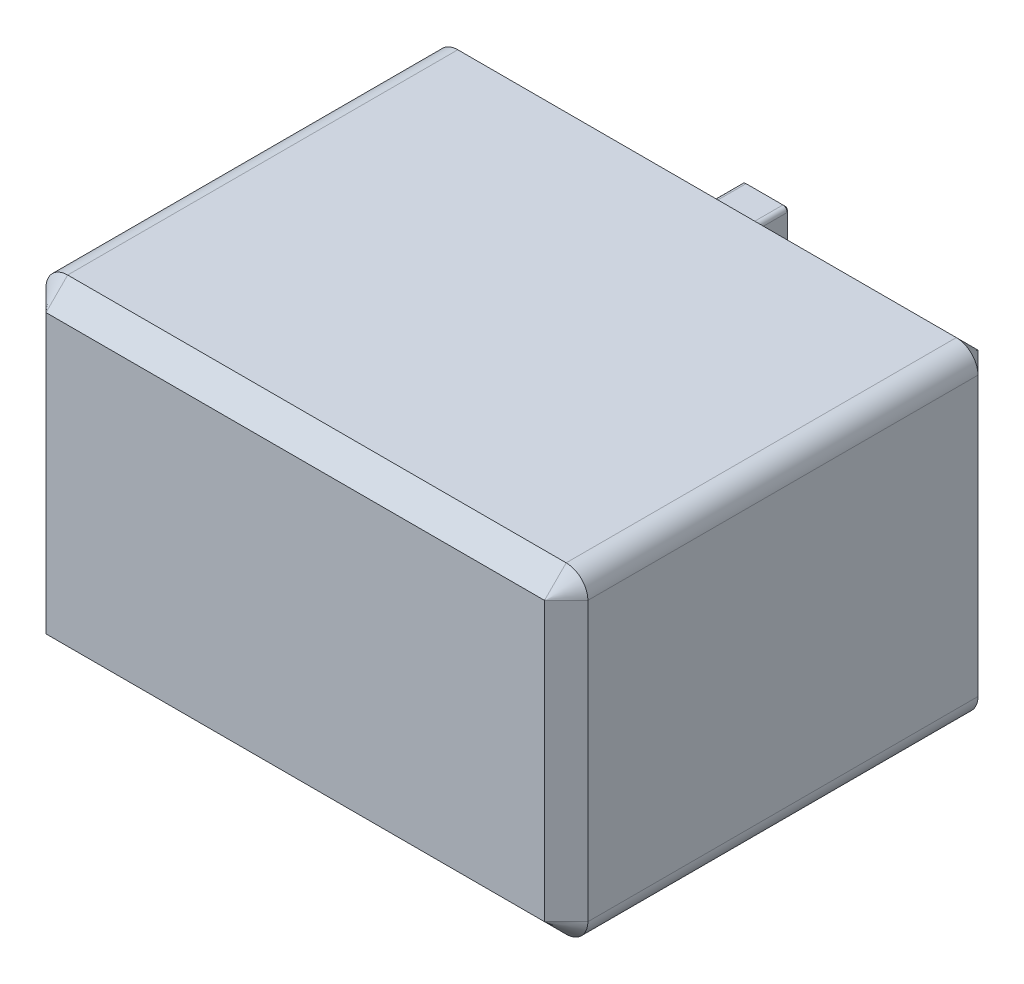
from build123d import *

# Parameters (mm, degrees)
MAIN_FEATURES_W        = 2.1
MAIN_FEATURES_H        = 2.5
PEG_DEPTH              = 1.75
SKETCH1_3_W            = 25
SKETCH1_3_H            = 14.84
BLOCK_DEPTH            = 20
ROUNDED_PEG_EDGES_R    = 0.2
ROUNDED_BLOCK_EDGES_R  = 1
BREAK_PEG_EDGES_SIZE   = 0.1
BREAK_BLOCK_EDGES_SIZE = 1


with BuildPart() as part:
    # main_features → peg (new body)
    with BuildSketch(Plane.XY):
        with Locations((0, 12.44)):
            Rectangle(MAIN_FEATURES_W, MAIN_FEATURES_H)
    extrude(amount=-PEG_DEPTH)

    # Sketch1_3 → block (add)
    with BuildSketch(Plane.XY):
        with Locations((0, 7.62)):
            Rectangle(SKETCH1_3_W, SKETCH1_3_H)
    extrude(amount=BLOCK_DEPTH)

    # rounded_peg_edges
    rounded_peg_edges_edges = [part.edges().sort_by_distance(p)[0] for p in [
        (-1.05, 11.19, -0.875),
        (1.05, 11.19, -0.875),
        (1.05, 13.69, -0.875),
        (-1.05, 13.69, -0.875),
    ]]
    fillet(rounded_peg_edges_edges, radius=ROUNDED_PEG_EDGES_R)

    # rounded_block_edges
    rounded_block_edges_edges = [part.edges().sort_by_distance(p)[0] for p in [
        (-12.5, 0.2, 10),
        (12.5, 0.2, 10),
        (12.5, 15.04, 10),
        (-12.5, 15.04, 10),
    ]]
    fillet(rounded_block_edges_edges, radius=ROUNDED_BLOCK_EDGES_R)

    # break_peg_edges
    break_peg_edges_edges = [part.edges().sort_by_distance(p)[0] for p in [
        (0, 11.19, -1.75),
        (1.05, 12.44, -1.75),
        (0, 13.69, -1.75),
        (-1.05, 12.44, -1.75),
        (-0.991421356, 13.631421356, -1.75),
        (-0.991421356, 11.248578644, -1.75),
        (0.991421356, 13.631421356, -1.75),
        (0.991421356, 11.248578644, -1.75),
    ]]
    chamfer(break_peg_edges_edges, length=BREAK_PEG_EDGES_SIZE)

    # break_block_edges
    break_block_edges_edges = [part.edges().sort_by_distance(p)[0] for p in [
        (12.5, 7.62, 0),
        (12.5, 7.62, 20),
        (0, 0.2, 0),
        (-12.5, 7.62, 0),
        (0, 15.04, 0),
        (-12.207106781, 0.492893219, 0),
        (-12.207106781, 14.747106781, 0),
        (12.207106781, 14.747106781, 0),
        (12.207106781, 0.492893219, 0),
        (0, 0.2, 20),
        (0, 15.04, 20),
        (-12.5, 7.62, 20),
        (-12.207106781, 0.492893219, 20),
        (-12.207106781, 14.747106781, 20),
        (12.207106781, 14.747106781, 20),
        (12.207106781, 0.492893219, 20),
    ]]
    chamfer(break_block_edges_edges, length=BREAK_BLOCK_EDGES_SIZE)


solid = part.part
